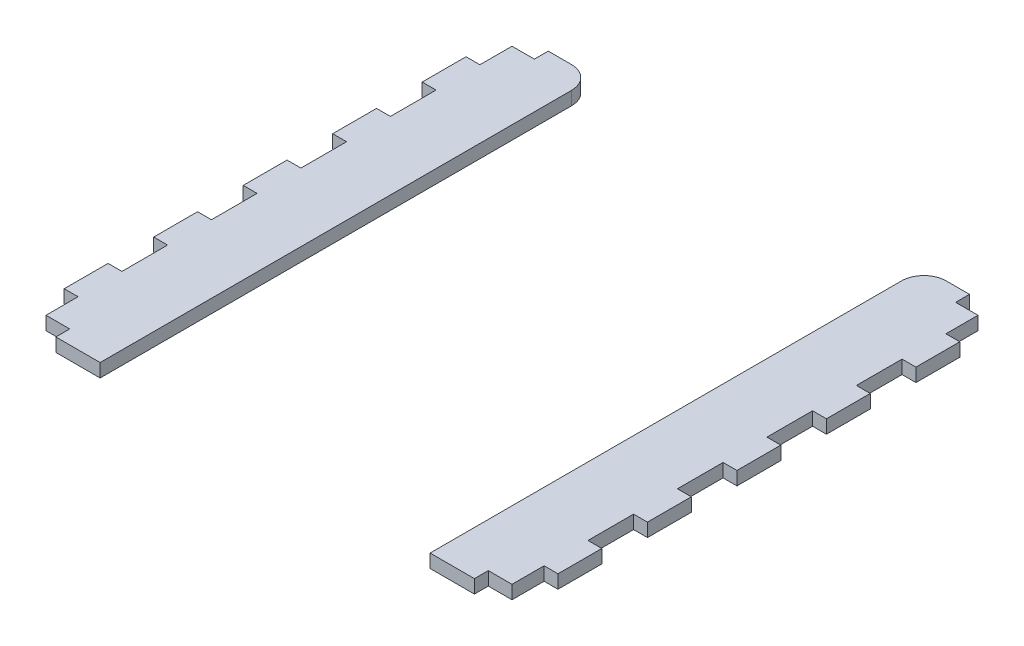
from build123d import *

# Parameters (mm, degrees)
BOSS_EXTRUDE1_DEPTH   = 3
BOSS_EXTRUDE1_2_DEPTH = 3
SKETCH2_W             = 3.2
SKETCH2_H             = 10.2
CUT_EXTRUDE1_DEPTH    = 4


with BuildPart() as part:
    # Sketch1 → Boss-Extrude1 (new body)
    with BuildSketch(Plane(origin=(0, 0, 0), x_dir=(1, 0, 0), z_dir=(0, 1, 0))):
        with BuildLine():
            Line((36.872217102, -66.842990858), (55.172217102, -66.842990858))
            Line((55.172217102, -66.842990858), (55.172217102, 43.501443346))
            Line((55.172217102, 43.501443346), (41.872217102, 43.501443346))
            ThreePointArc((41.872217102, 43.501443346), (38.336683196, 42.036977252), (36.872217102, 38.501443346))
            Line((36.872217102, 38.501443346), (36.872217102, -66.842990858))
        make_face()
    extrude(amount=BOSS_EXTRUDE1_DEPTH)


with BuildPart() as body_2:
    # Sketch1 → Boss-Extrude1 2 (new body)
    with BuildSketch(Plane(origin=(0, 0, 0), x_dir=(1, 0, 0), z_dir=(0, 1, 0))):
        with BuildLine():
            Line((-55.172217102, 43.501443346), (-41.872217102, 43.501443346))
            ThreePointArc((-41.872217102, 43.501443346), (-38.336683196, 42.036977252), (-36.872217102, 38.501443346))
            Line((-36.872217102, 38.501443346), (-36.872217102, -66.842990858))
            Line((-36.872217102, -66.842990858), (-55.172217102, -66.842990858))
            Line((-55.172217102, -66.842990858), (-55.172217102, 43.501443346))
        make_face()
    extrude(amount=BOSS_EXTRUDE1_2_DEPTH)


with BuildPart() as cut_extrude1_tool:
    # Sketch2 → Cut-Extrude1 (new body, through all)
    with BuildSketch(Plane(origin=(0, 0, 0), x_dir=(1, 0, 0), z_dir=(0, 1, 0))):
        Polygon((-52.072217102, -56.570773756), (-52.072217102, -63.742990858), (-46.772217102, -63.742990858), (-46.772217102, -66.942990858), (-55.272217102, -66.942990858), (-55.272217102, -56.570773756), align=None)
        with Locations((-53.672217102, -1.670773756)):
            Rectangle(SKETCH2_W, SKETCH2_H)
        with Locations((-53.672217102, 18.329226244)):
            Rectangle(SKETCH2_W, SKETCH2_H)
        with Locations((-53.672217102, -21.670773756)):
            Rectangle(SKETCH2_W, SKETCH2_H)
        with Locations((-53.672217102, -41.670773756)):
            Rectangle(SKETCH2_W, SKETCH2_H)
        with Locations((53.672217102, -41.670773756)):
            Rectangle(SKETCH2_W, SKETCH2_H)
        with Locations((53.672217102, -21.670773756)):
            Rectangle(SKETCH2_W, SKETCH2_H)
        Polygon((52.072217102, -63.742990858), (46.772217102, -63.742990858), (46.772217102, -66.942990858), (55.272217102, -66.942990858), (55.272217102, -56.570773756), (52.072217102, -56.570773756), align=None)
        with Locations((53.672217102, 18.329226244)):
            Rectangle(SKETCH2_W, SKETCH2_H)
        Polygon((52.072217102, 40.401443346), (52.072217102, 33.229226244), (55.272217102, 33.229226244), (55.272217102, 43.601443346), (47.072217102, 43.601443346), (47.072217102, 40.401443346), align=None)
        with Locations((53.672217102, -1.670773756)):
            Rectangle(SKETCH2_W, SKETCH2_H)
        Polygon((-52.072217102, 33.229226244), (-55.272217102, 33.229226244), (-55.272217102, 43.601443346), (-47.072217102, 43.601443346), (-47.072217102, 40.401443346), (-52.072217102, 40.401443346), align=None)
    extrude(amount=CUT_EXTRUDE1_DEPTH)


with BuildPart() as part_1:
    add(part.part)

    # Cut-Extrude1: cut by cut_extrude1_tool
    add(cut_extrude1_tool.part, mode=Mode.SUBTRACT)


with BuildPart() as body_2_1:
    add(body_2.part)

    # Cut-Extrude1: cut by cut_extrude1_tool
    add(cut_extrude1_tool.part, mode=Mode.SUBTRACT)


solid = Compound([part_1.part, body_2_1.part])
